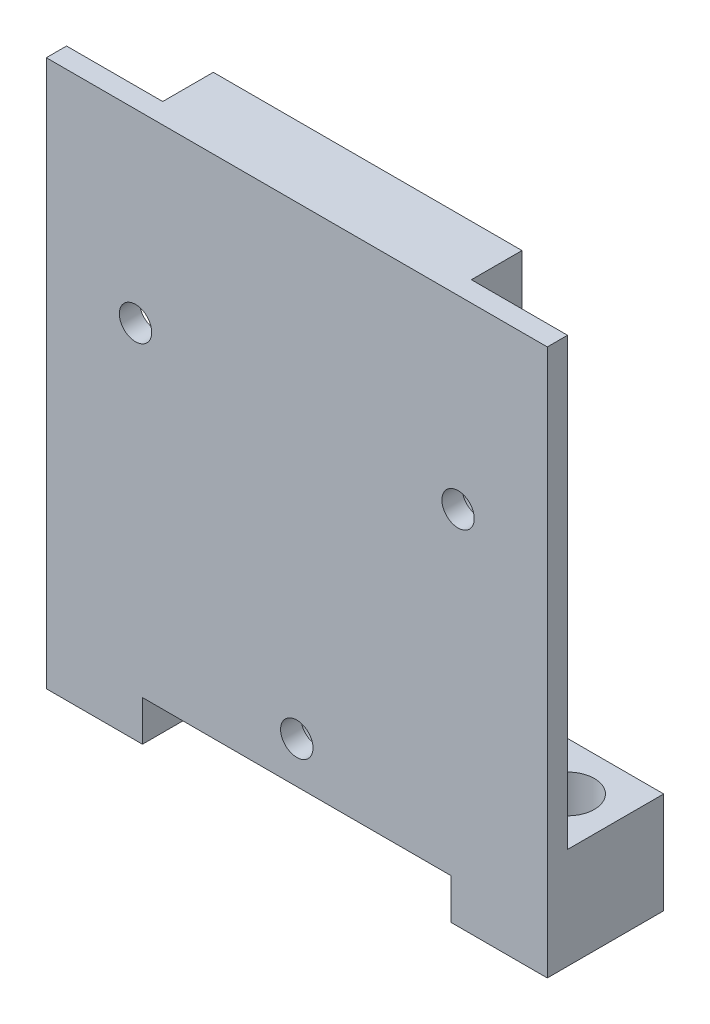
from build123d import *

# Parameters (mm, degrees)
SKETCH2_W             = 9.5
SKETCH2_H             = 9.5
SKETCH2_R             = 2.65
BOSS_EXTRUDE1_DEPTH   = 10
BOSS_EXTRUDE1_2_DEPTH = 10
SKETCH13_W            = 49.5
SKETCH13_H            = 50
BOSS_EXTRUDE4_DEPTH   = 2
CUT_EXTRUDE3_START    = 2
SKETCH12_R            = 1.6
CUT_EXTRUDE3_DEPTH    = 2
SKETCH14_R            = 3
BOSS_EXTRUDE5_DEPTH   = 5
SKETCH15_W            = 9.5
SKETCH15_H            = 4
BOSS_EXTRUDE6_DEPTH   = 2


with BuildPart() as part:
    # Sketch2 → Boss-Extrude1 (new body)
    with BuildSketch(Plane(origin=(0, 0, 0), x_dir=(1, 0, 0), z_dir=(0, 1, 0))):
        with Locations((4.75, 4.75)):
            Rectangle(SKETCH2_W, SKETCH2_H)
        with Locations((4.75, 4.75)):
            Circle(SKETCH2_R, mode=Mode.SUBTRACT)
    extrude(amount=BOSS_EXTRUDE1_DEPTH)



with BuildPart() as body_2:
    # Sketch2 → Boss-Extrude1 2 (new body)
    with BuildSketch(Plane(origin=(0, 0, 0), x_dir=(1, 0, 0), z_dir=(0, 1, 0))):
        with Locations((44.75, 4.75)):
            Rectangle(SKETCH2_W, SKETCH2_H)
        with Locations((44.75, 4.75)):
            Circle(SKETCH2_R, mode=Mode.SUBTRACT)
    extrude(amount=BOSS_EXTRUDE1_2_DEPTH)


with BuildPart() as part_1:
    add(part.part)

    add(body_2.part)  # Boss-Extrude4 merges body 2
    # Sketch13 → Boss-Extrude4 (add)
    with BuildSketch(Plane.XY):
        with Locations((24.75, 29)):
            Rectangle(SKETCH13_W, SKETCH13_H)
    extrude(amount=BOSS_EXTRUDE4_DEPTH)

    # Sketch12 → Cut-Extrude3 (cut)
    with BuildSketch(Plane.XY.offset(CUT_EXTRUDE3_START)):
        with Locations((24.75, 8.1)):
            Circle(SKETCH12_R)
        with Locations((8.81513257, 35.7)):
            Circle(SKETCH12_R)
        with Locations((40.68486743, 35.7)):
            Circle(SKETCH12_R)
    extrude(amount=-CUT_EXTRUDE3_DEPTH, mode=Mode.SUBTRACT)

    # Sketch14 → Boss-Extrude5 (add)
    with BuildSketch(Plane(origin=(0, 0, 0), x_dir=(-1, 0, 0), z_dir=(0, 0, -1))):
        with BuildLine():
            Line((-9.5, 54), (-40, 54))
            Line((-40, 54), (-40, 38.620780136))
            ThreePointArc((-40, 38.620780136), (-38.333846131, 37.563517871), (-37.68486743, 35.7))
            ThreePointArc((-37.68486743, 35.7), (-38.333846131, 33.836482129), (-40, 32.779219864))
            Line((-40, 32.779219864), (-40, 10))
            Line((-40, 10), (-40, 4))
            Line((-40, 4), (-9.5, 4))
            Line((-9.5, 4), (-9.5, 10))
            Line((-9.5, 10), (-9.5, 32.779219864))
            ThreePointArc((-9.5, 32.779219864), (-11.81513257, 35.7), (-9.5, 38.620780136))
            Line((-9.5, 38.620780136), (-9.5, 54))
        make_face()
        with Locations((-24.75, 8.1)):
            Circle(SKETCH14_R, mode=Mode.SUBTRACT)
    extrude(amount=BOSS_EXTRUDE5_DEPTH)

    # Sketch15 → Boss-Extrude6 (add)
    with BuildSketch(Plane.XY):
        with Locations((4.75, 2)):
            Rectangle(SKETCH15_W, SKETCH15_H)
        with Locations((44.75, 2)):
            Rectangle(SKETCH15_W, SKETCH15_H)
    extrude(amount=BOSS_EXTRUDE6_DEPTH)


solid = part_1.part
